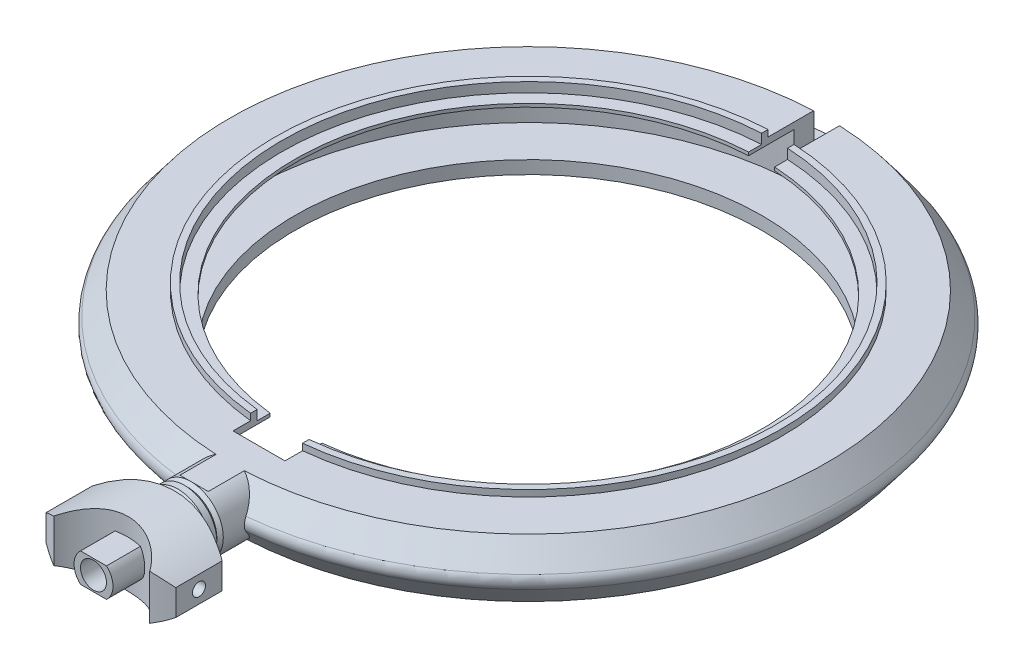
from build123d import *

# Parameters (mm, degrees)
CORTAR_EXTRUIR1_DEPTH                       = 36.08204683
CORTAR_EXTRUIR1_DEPTH_BACK                  = 36.08204683
CROQUIS3_W                                  = 4
CROQUIS3_H                                  = 3.25
CORTAR_EXTRUIR2_DEPTH                       = 36.08204683
CORTAR_EXTRUIR3_DEPTH                       = 38.983549135
CORTAR_EXTRUIR3_DEPTH_BACK                  = 38.983549135
SALIENTE_EXTRUIR1_DEPTH                     = 2.5
SALIENTE_EXTRUIR1_DEPTH_BACK                = 2.5
CROQUIS9_W                                  = 3
CROQUIS9_H                                  = 7
CORTAR_EXTRUIR5_DEPTH                       = 42.865857269
CORTAR_EXTRUIR6_DEPTH                       = 6.5
CROQUIS12_R                                 = 4.45
CORTAR_EXTRUIR7_DEPTH                       = 6.5
CORTAR_EXTRUIR7_DEPTH_BACK                  = 6.5
SALIENTE_EXTRUIR2_REACH                     = 65.166
SALIENTE_EXTRUIR2_END_RADIUS                = 4.45
CROQUIS13_R                                 = 1
CORTAR_EXTRUIR8_DEPTH                       = 42.865857349
DI_METRO_DE_TALADRO_1_0_1_1_D               = 1
DI_METRO_DE_TALADRO_1_0_1_1_DEPTH           = 2
DI_METRO_DE_TALADRO_1_0_1_1_TIP             = 0.30043031
DI_METRO_DE_TALADRO_1_0_1_1_ON_FACE_2_D     = 1
DI_METRO_DE_TALADRO_1_0_1_1_ON_FACE_2_DEPTH = 2
DI_METRO_DE_TALADRO_1_0_1_1_ON_FACE_2_TIP   = 0.30043031
CORTAR_EXTRUIR9_START                       = -2.5
CROQUIS16_W                                 = 2
CROQUIS16_H                                 = 7
CORTAR_EXTRUIR9_DEPTH                       = 2.5


with BuildPart() as part:
    # Croquis1 → Revolución1 (revolve)
    with BuildSketch(Plane.XY, mode=Mode.PRIVATE) as revoluci_n1_sk:
        with BuildLine():
            Line((18, 0), (21, 0))
            Line((21, 0), (21, 0.5))
            Line((21, 0.5), (23, 0.5))
            Line((23, 0.5), (24.331419138, 2.25))
            ThreePointArc((24.331419138, 2.25), (24.5, 2.75), (24.331419138, 3.25))
            Line((24.331419138, 3.25), (23, 5))
            Line((23, 5), (19.5, 5))
            Line((19.5, 5), (19.5, 5.5))
            Line((19.5, 5.5), (19, 5.5))
            Line((19, 5.5), (19, 4.75))
            Line((19, 4.75), (18, 4.75))
            Line((18, 4.75), (18, 4.5))
            Line((18, 4.5), (21.5, 4.5))
            Line((21.5, 4.5), (21.5, 1))
            Line((21.5, 1), (18, 1))
            Line((18, 1), (18, 0))
        make_face()
    revolve(revoluci_n1_sk.sketch.rotate(Axis((0, 0, 0), (0, 1, 0)), 90), axis=Axis((0, 0, 0), (0, 1, 0)))

    # Croquis2 → Cortar-Extruir1 (cut, two sides)
    with BuildSketch(Plane(origin=(0, 0, 0), x_dir=(0, 0, -1), z_dir=(1, 0, 0))) as cortar_extruir1_sk:
        with BuildLine():
            Line((23, 3), (23, 5))
            Line((23, 5), (24.5, 5))
            Line((24.5, 5), (24.5, 2.5))
            Line((24.5, 2.5), (23.5, 2.5))
            ThreePointArc((23.5, 2.5), (23.146446609, 2.646446609), (23, 3))
        make_face()
    extrude(amount=CORTAR_EXTRUIR1_DEPTH, mode=Mode.SUBTRACT)
    extrude(cortar_extruir1_sk.sketch, amount=-CORTAR_EXTRUIR1_DEPTH_BACK, mode=Mode.SUBTRACT)

    # Croquis3 → Cortar-Extruir2 (cut, through all)
    with BuildSketch(Plane.XZ):
        with Locations((0, 19.125)):
            Rectangle(CROQUIS3_W, CROQUIS3_H)
    extrude(amount=-CORTAR_EXTRUIR2_DEPTH, mode=Mode.SUBTRACT)

    # Croquis5 → Revolución2 (revolve)
    with BuildSketch(Plane(origin=(0, 0, 0), x_dir=(0, 0, -1), z_dir=(1, 0, 0))):
        Polygon((-22, 0.25), (-22, 2.75), (-28.5, 2.75), (-28.5, 0.25), (-28, 0.25), (-27.5, 0.75), (-27, 0.25), (-26.5, 0.25), (-26.25, 0.5), (-26, 0.25), align=None)
    revolve(axis=Axis((0, 2.75, 28.5), (0, 0, -1)))

    # Croquis6 → Cortar-Extruir3 (cut, two sides)
    with BuildSketch(Plane(origin=(0, 0, 0), x_dir=(0, 0, -1), z_dir=(1, 0, 0))) as cortar_extruir3_sk:
        Polygon((-22, 0), (-22, 0.5), (-25.75, 0.5), (-26.25, 0), (-26.25, -0.75), (-22, -0.75), align=None)
        Polygon((-22, 5), (-25.75, 5), (-26.25, 5.5), (-26.25, 6.25), (-22, 6.25), (-22, 5.5), align=None)
        Polygon((-28, 5.25), (-28.5, 4.75), (-28.5, 5.25), align=None)
        Polygon((-28, 0.25), (-28.5, 0.75), (-28.5, 0.25), align=None)
    extrude(amount=CORTAR_EXTRUIR3_DEPTH, mode=Mode.SUBTRACT)
    extrude(cortar_extruir3_sk.sketch, amount=-CORTAR_EXTRUIR3_DEPTH_BACK, mode=Mode.SUBTRACT)

    # Croquis8 → Saliente-Extruir1 (add, two sides)
    with BuildSketch(Plane(origin=(0, 2.75, 0), x_dir=(-1, 0, 0), z_dir=(0, 1, 0))) as saliente_extruir1_sk:
        with BuildLine():
            ThreePointArc((-7.261843774, 30.375), (0, 27.25), (7.261843774, 30.375))
            ThreePointArc((7.261843774, 30.375), (0, 33.5), (-7.261843774, 30.375))
        make_face()
    extrude(amount=SALIENTE_EXTRUIR1_DEPTH)
    extrude(saliente_extruir1_sk.sketch, amount=-SALIENTE_EXTRUIR1_DEPTH_BACK)

    # Croquis9 → Cortar-Extruir5 (cut, through all)
    with BuildSketch(Plane(origin=(0, 0, 0), x_dir=(1, 0, 0), z_dir=(0, 1, 0))):
        with Locations((6.5, -29.5)):
            Rectangle(CROQUIS9_W, CROQUIS9_H)
        with Locations((-6.5, -29.5)):
            Rectangle(CROQUIS9_W, CROQUIS9_H)
    extrude(amount=CORTAR_EXTRUIR5_DEPTH, mode=Mode.SUBTRACT)

    # Croquis10 → Cortar-Extruir6 (cut)
    with BuildSketch(Plane.XY.offset(33.5)):
        with BuildLine():
            Line((5, 5.25), (0, 5.25))
            ThreePointArc((0, 5.25), (2.610076627, 4.866922091), (5, 3.75))
            Line((5, 3.75), (5, 5.25))
        make_face()
        with BuildLine():
            Line((-5, 5.25), (-5, 3.75))
            ThreePointArc((-5, 3.75), (-2.610076627, 4.866922091), (0, 5.25))
            Line((0, 5.25), (-5, 5.25))
        make_face()
        with BuildLine():
            ThreePointArc((0, 0.25), (-2.610076627, 0.633077909), (-5, 1.75))
            Line((-5, 1.75), (-5, 0.25))
            Line((-5, 0.25), (0, 0.25))
        make_face()
        with BuildLine():
            ThreePointArc((5, 1.75), (2.610076627, 0.633077909), (0, 0.25))
            Line((0, 0.25), (5, 0.25))
            Line((5, 0.25), (5, 1.75))
        make_face()
    extrude(amount=-CORTAR_EXTRUIR6_DEPTH, mode=Mode.SUBTRACT)

    # Croquis12 → Cortar-Extruir7 (cut, two sides)
    with BuildSketch(Plane(origin=(0, 2.75, 0), x_dir=(-1, 0, 0), z_dir=(0, 1, 0))) as cortar_extruir7_sk:
        with Locations((0.113074667, 35.198563152)):
            Circle(CROQUIS12_R)
    extrude(amount=CORTAR_EXTRUIR7_DEPTH, mode=Mode.SUBTRACT)
    extrude(cortar_extruir7_sk.sketch, amount=-CORTAR_EXTRUIR7_DEPTH_BACK, mode=Mode.SUBTRACT)

    # Saliente-Extruir2: up to this cylinder (the profile starts inside it)
    saliente_extruir2_end = Plane(origin=(-0.113074667, 2.75, 35.198563152), z_dir=(0, -1, 0)) * Cylinder(SALIENTE_EXTRUIR2_END_RADIUS, 140.232, mode=Mode.PRIVATE)
    # Croquis15 → Saliente-Extruir2 (add, up to the surface)
    with BuildSketch(Plane.XY.offset(33.5), mode=Mode.PRIVATE) as saliente_extruir2_sk1:
        with BuildLine():
            Line((-1, 3.868033989), (1, 3.868033989))
            ThreePointArc((1, 3.868033989), (1.5, 2.75), (1, 1.631966011))
            Line((1, 1.631966011), (-1, 1.631966011))
            ThreePointArc((-1, 1.631966011), (-1.5, 2.75), (-1, 3.868033989))
        make_face()
    saliente_extruir2_tool1 = extrude(saliente_extruir2_sk1.sketch, amount=-SALIENTE_EXTRUIR2_REACH, mode=Mode.PRIVATE) & saliente_extruir2_end
    add(saliente_extruir2_tool1.solids().sort_by_distance((0, 2.75, 33.5))[0])

    # Croquis13 → Cortar-Extruir8 (cut, through all)
    with BuildSketch(Plane.XY):
        with Locations(Location((0, 2.75, 0), (0, 0, 180))):
            Circle(CROQUIS13_R)
    extrude(amount=CORTAR_EXTRUIR8_DEPTH, mode=Mode.SUBTRACT)

    # Diámetro de taladro Ø1.0 (1)1
    with Locations(Plane(origin=(5, 2.75, 30.375), x_dir=(0, 0, 1), z_dir=(1, 0, 0))):
        with Locations((0, 0)):
            Hole(DI_METRO_DE_TALADRO_1_0_1_1_D / 2, depth=DI_METRO_DE_TALADRO_1_0_1_1_DEPTH)
            with Locations((0, 0, -(DI_METRO_DE_TALADRO_1_0_1_1_DEPTH + DI_METRO_DE_TALADRO_1_0_1_1_TIP / 2))):  # 118° drill point
                Cone(0, DI_METRO_DE_TALADRO_1_0_1_1_D / 2, DI_METRO_DE_TALADRO_1_0_1_1_TIP, mode=Mode.SUBTRACT)

    # Diámetro de taladro Ø1.0 (1)1 on face 2
    with Locations(Plane(origin=(-5, 2.75, 30.375), x_dir=(0, 0, -1), z_dir=(-1, 0, 0))):
        with Locations((0, 0)):
            Hole(DI_METRO_DE_TALADRO_1_0_1_1_ON_FACE_2_D / 2, depth=DI_METRO_DE_TALADRO_1_0_1_1_ON_FACE_2_DEPTH)
            with Locations((0, 0, -(DI_METRO_DE_TALADRO_1_0_1_1_ON_FACE_2_DEPTH + DI_METRO_DE_TALADRO_1_0_1_1_ON_FACE_2_TIP / 2))):  # 118° drill point
                Cone(0, DI_METRO_DE_TALADRO_1_0_1_1_ON_FACE_2_D / 2, DI_METRO_DE_TALADRO_1_0_1_1_ON_FACE_2_TIP, mode=Mode.SUBTRACT)

    # Croquis16 → Cortar-Extruir9 (cut)
    with BuildSketch(Plane(origin=(0, 5.5, 0), x_dir=(1, 0, 0), z_dir=(0, 1, 0)).offset(CORTAR_EXTRUIR9_START)):
        with Locations((0, 19.5)):
            Rectangle(CROQUIS16_W, CROQUIS16_H)
    extrude(amount=CORTAR_EXTRUIR9_DEPTH, mode=Mode.SUBTRACT)


solid = part.part
